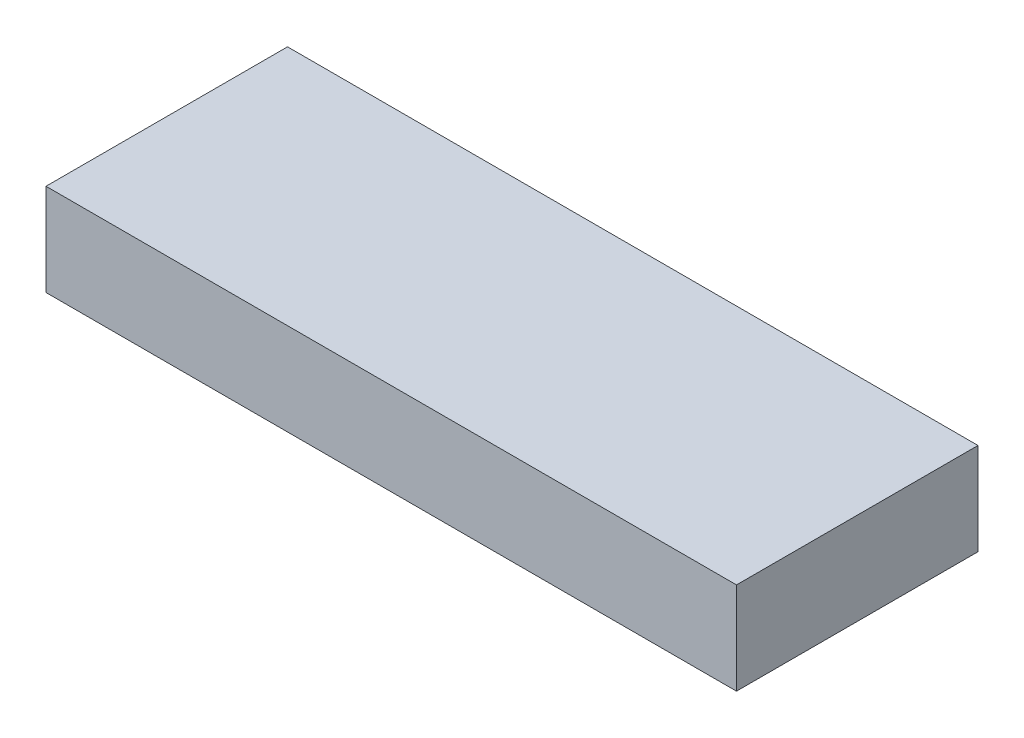
from build123d import *

# Parameters (mm, degrees)
SKETCH1_W           = 47.63
SKETCH1_H           = 16.66
BOSS_EXTRUDE1_DEPTH = 6.35


with BuildPart() as part:
    # Sketch1 → Boss-Extrude1 (new body)
    with BuildSketch(Plane(origin=(0, 0, 0), x_dir=(1, 0, 0), z_dir=(0, 1, 0))):
        with Locations((23.815, 8.33)):
            Rectangle(SKETCH1_W, SKETCH1_H)
    extrude(amount=BOSS_EXTRUDE1_DEPTH)


solid = part.part
